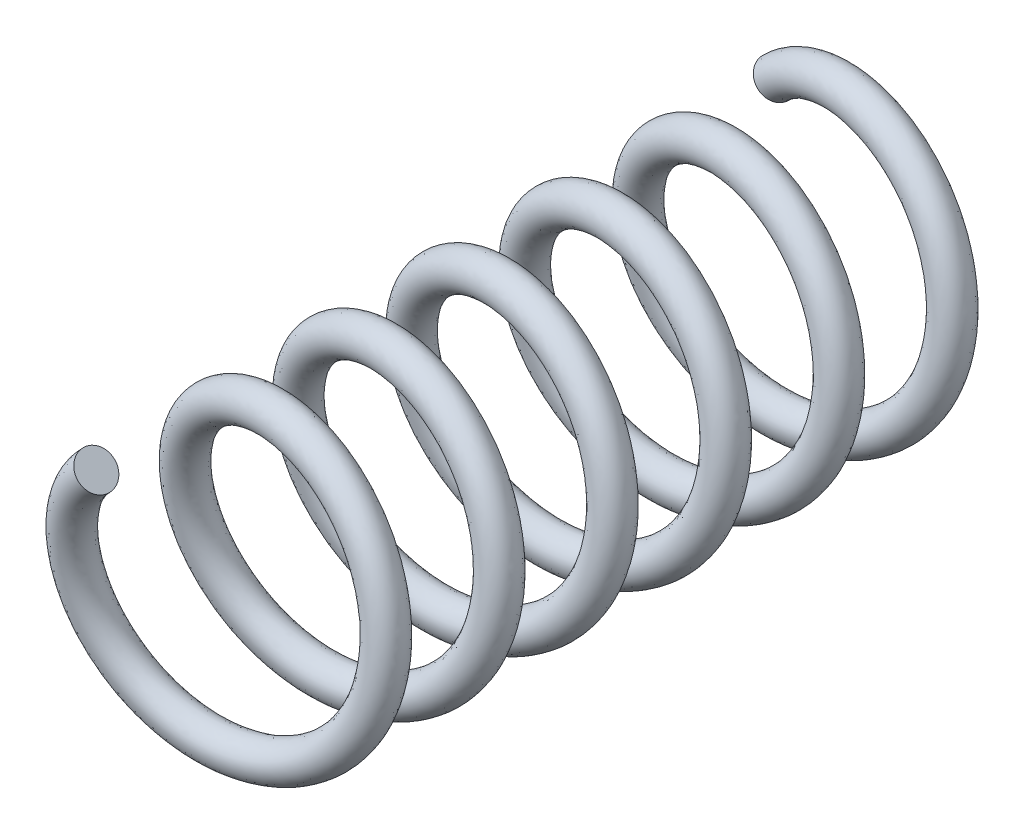
from build123d import *

# Parameters (mm, degrees)
BALAYAGE1_PITCH       = 4
BALAYAGE1_HEIGHT      = 24
BALAYAGE1_RADIUS      = 0.5
BALAYAGE1_START_ANGLE = 135
ESQUISSE3_R           = 0.65


with BuildPart() as part:
    # Balayage1: sweep along a helix
    with BuildLine() as balayage1_path:
        add(Helix(BALAYAGE1_PITCH, BALAYAGE1_HEIGHT, BALAYAGE1_RADIUS, center=(0, 0, 0), direction=(0, 0, 1), lefthand=True, mode=Mode.PRIVATE).rotate(Axis((0, 0, 0), (0, 0, 1)), BALAYAGE1_START_ANGLE))
    # Esquisse3 → Balayage1 (sweep)
    with BuildSketch(Plane(origin=(0, 0, 0), x_dir=(1, 0, 0), z_dir=(0, 1, 0))):
        with Locations((4.5, 0)):
            Circle(ESQUISSE3_R)
    sweep(path=balayage1_path.line, is_frenet=True)


solid = part.part
